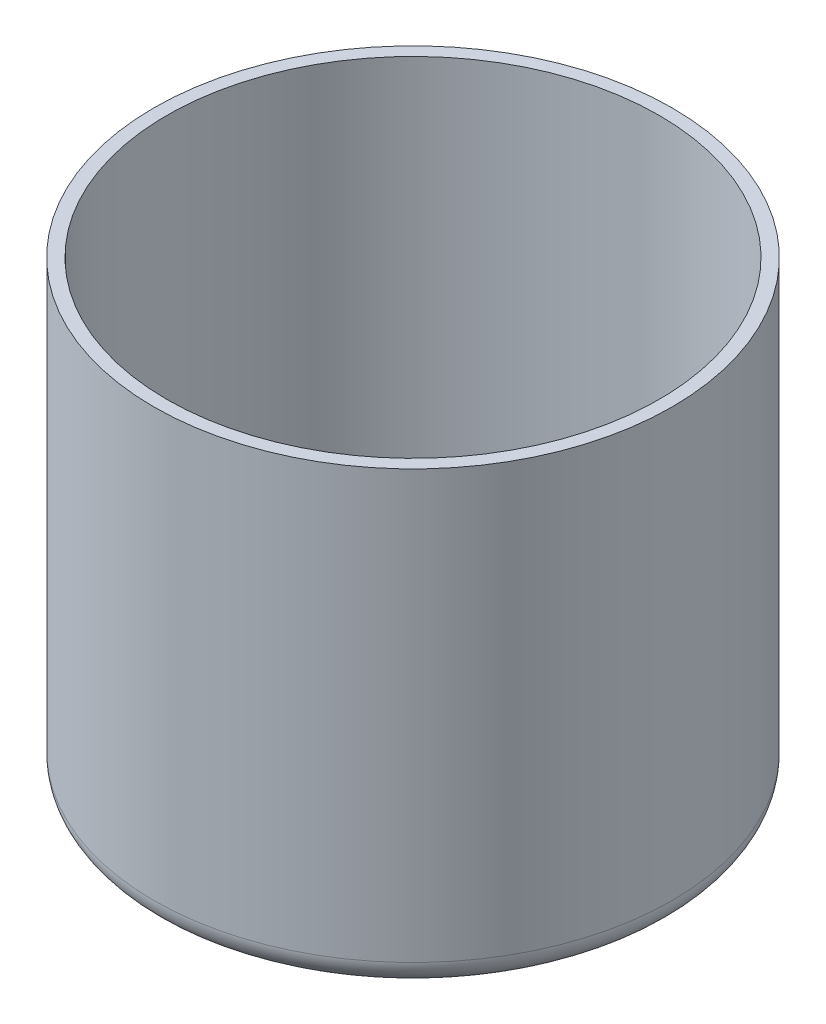
from build123d import *

# Parameters (mm, degrees)
FILLET1_R = 2


with BuildPart() as part:
    # Sketch1 → Revolve1 (revolve)
    with BuildSketch(Plane.XY):
        Polygon((-20, 2.423201416), (-20, -32.576798584), (0, -32.576798584), (0, -31.576798584), (-19, -31.576798584), (-19, 2.423201416), align=None)
    revolve(axis=Axis((0, 0, 0), (0, 1, 0)))

    # Fillet1
    fillet1_edges = [part.edges().sort_by_distance(p)[0] for p in [
        (20, -32.576798584, 0),
    ]]
    fillet(fillet1_edges, radius=FILLET1_R)


solid = part.part
